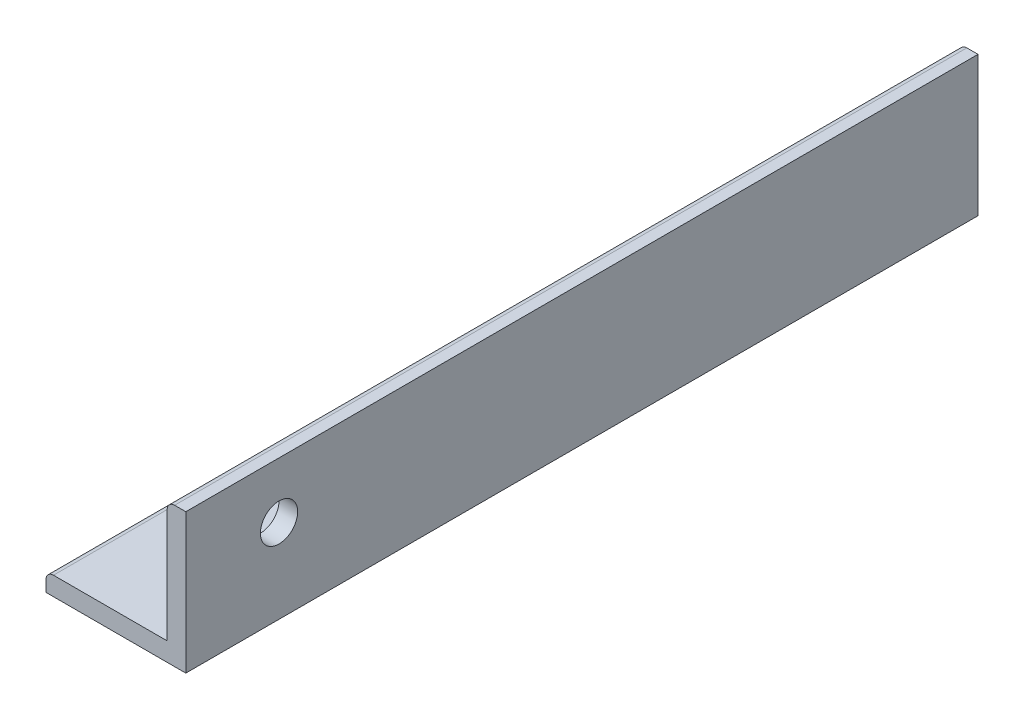
from build123d import *

# Parameters (mm, degrees)
EXTRUDE_1_DEPTH     = 85
FILLET_1_R          = 0.8
SKETCH_2_R          = 2
CUT_EXTRUDE_1_DEPTH = 2
SKETCH_3_R          = 2
CUT_EXTRUDE_2_DEPTH = 400


with BuildPart() as part:
    # 草图1 → 凸台-拉伸1 (new body)
    with BuildSketch(Plane.XY):
        Polygon((0, 0), (0, 15), (-2, 15), (-2, 2), (-15, 2), (-15, 0), align=None)
    extrude(amount=EXTRUDE_1_DEPTH)

    # 圆角1
    fillet_1_edges = [part.edges().sort_by_distance(p)[0] for p in [
        (-15, 2, 42.5),
        (-2, 15, 42.5),
    ]]
    fillet(fillet_1_edges, radius=FILLET_1_R)

    # 草图2 → 切除-拉伸1 (cut)
    with BuildSketch(Plane(origin=(0, 2, 0), x_dir=(1, 0, 0), z_dir=(0, 1, 0))):
        with Locations((-8, -15)):
            Circle(SKETCH_2_R)
    extrude(amount=-CUT_EXTRUDE_1_DEPTH, mode=Mode.SUBTRACT)

    # 草图3 → 切除-拉伸2 (cut)
    with BuildSketch(Plane.ZY.offset(2)):
        with Locations((75, 9)):
            Circle(SKETCH_3_R)
    extrude(amount=-CUT_EXTRUDE_2_DEPTH, mode=Mode.SUBTRACT)


solid = part.part
